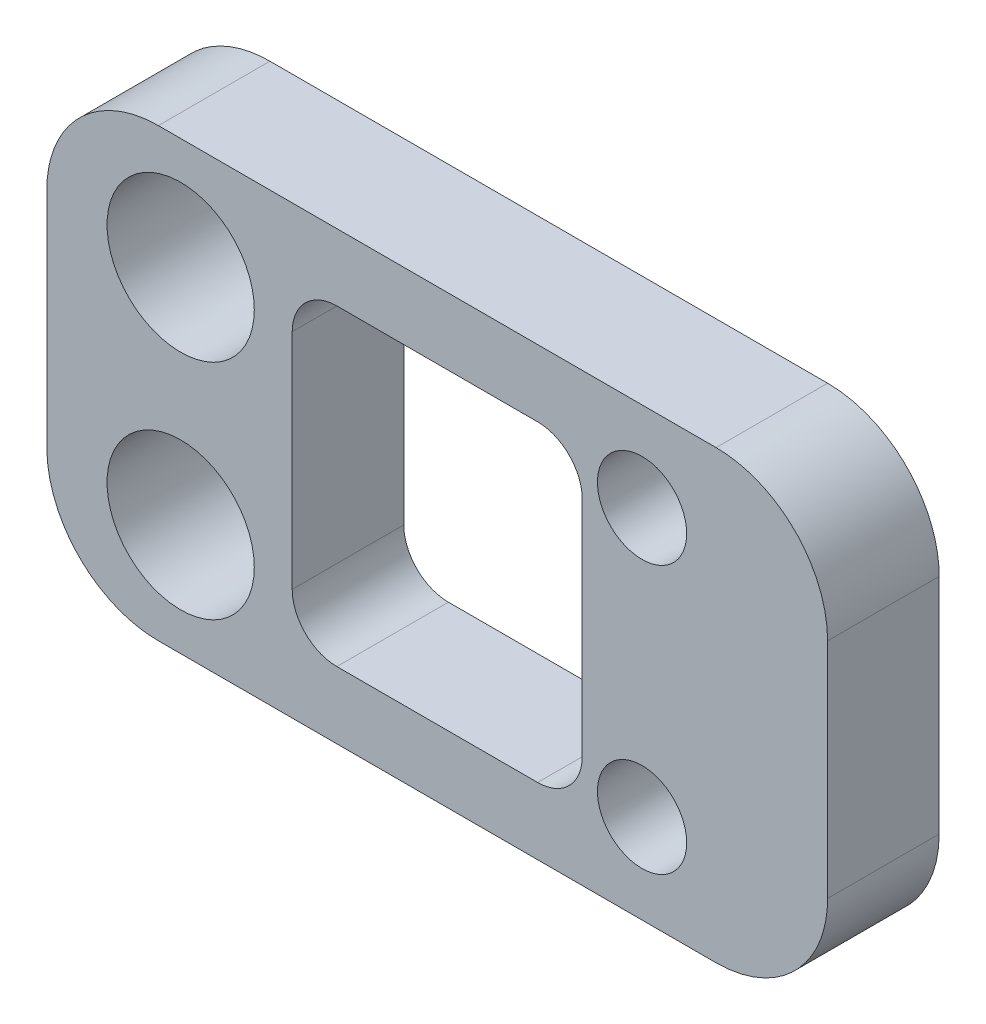
from build123d import *

# Parameters (mm, degrees)
ESQUISSE1_W             = 35
ESQUISSE1_H             = 20
BOSS_EXTRU_1_DEPTH      = 5
CONG_1_R                = 5
ESQUISSE7_R             = 2
ENL_V_MAT_EXTRU_2_DEPTH = 10
ESQUISSE6_R             = 3.3
ENL_V_MAT_EXTRU_3_DEPTH = 10
ESQUISSE9_W             = 13
ESQUISSE9_H             = 14
ENL_V_MAT_EXTRU_5_DEPTH = 10
CONG_2_R                = 2


with BuildPart() as part:
    # Esquisse1 → Boss.-Extru.1 (new body)
    with BuildSketch(Plane.XY):
        with Locations((-31.272929194, 23.850830526)):
            Rectangle(ESQUISSE1_W, ESQUISSE1_H)
    extrude(amount=BOSS_EXTRU_1_DEPTH)

    # Congé1
    cong_1_edges = [part.edges().sort_by_distance(p)[0] for p in [
        (-13.772929194, 13.850830526, 2.5),
        (-48.772929194, 13.850830526, 2.5),
        (-48.772929194, 33.850830526, 2.5),
        (-13.772929194, 33.850830526, 2.5),
    ]]
    fillet(cong_1_edges, radius=CONG_1_R)

    # Esquisse7 → Enlèv. mat.-Extru.2 (cut)
    with BuildSketch(Plane.XY.offset(5)):
        with Locations((-22.092006288, 29.850830526)):
            Circle(ESQUISSE7_R)
        with Locations((-22.092006288, 17.850830526)):
            Circle(ESQUISSE7_R)
    extrude(amount=-ENL_V_MAT_EXTRU_2_DEPTH, mode=Mode.SUBTRACT)

    # Esquisse6 → Enlèv. mat.-Extru.3 (cut)
    with BuildSketch(Plane.XY.offset(5)):
        with Locations((-42.772929194, 28.850830526)):
            Circle(ESQUISSE6_R)
        with Locations((-42.772929194, 18.850830526)):
            Circle(ESQUISSE6_R)
    extrude(amount=-ENL_V_MAT_EXTRU_3_DEPTH, mode=Mode.SUBTRACT)

    # Esquisse9 → Enlèv. mat.-Extru.5 (cut)
    with BuildSketch(Plane.XY.offset(5)):
        with Locations((-31.272929194, 23.850830526)):
            Rectangle(ESQUISSE9_W, ESQUISSE9_H)
    extrude(amount=-ENL_V_MAT_EXTRU_5_DEPTH, mode=Mode.SUBTRACT)

    # Congé2
    cong_2_edges = [part.edges().sort_by_distance(p)[0] for p in [
        (-24.772929194, 30.850830526, 2.5),
        (-24.772929194, 16.850830526, 2.5),
        (-37.772929194, 16.850830526, 2.5),
        (-37.772929194, 30.850830526, 2.5),
    ]]
    fillet(cong_2_edges, radius=CONG_2_R)


solid = part.part
